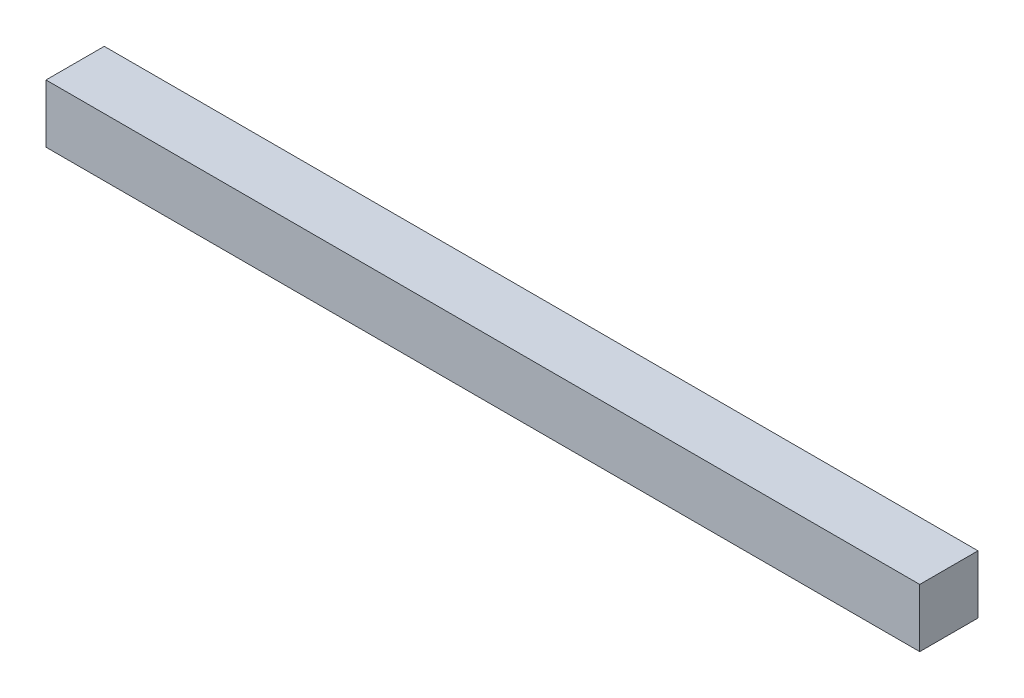
from build123d import *

# Parameters (mm, degrees)
SKETCH1_W           = 150
SKETCH1_H           = 10
BOSS_EXTRUDE1_DEPTH = 10


with BuildPart() as part:
    # Sketch1 → Boss-Extrude1 (new body)
    with BuildSketch(Plane.XY):
        Rectangle(SKETCH1_W, SKETCH1_H)
    extrude(amount=BOSS_EXTRUDE1_DEPTH)


solid = part.part
